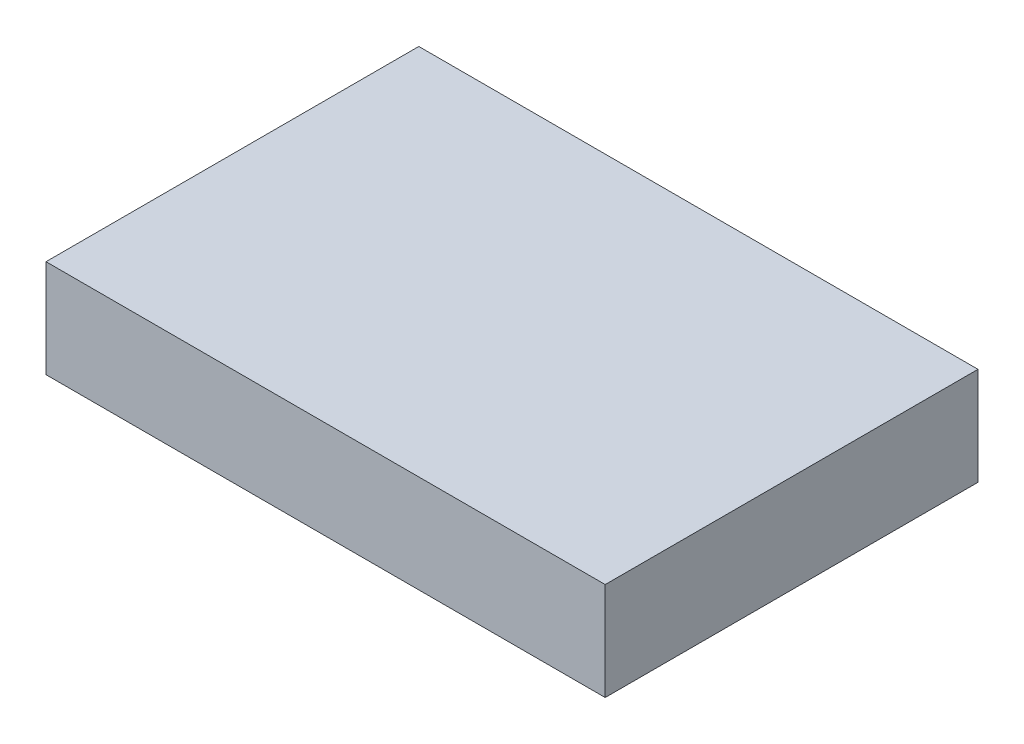
from build123d import *

# Parameters (mm, degrees)
SKETCH1_W           = 6
SKETCH1_H           = 4
BOSS_EXTRUDE1_DEPTH = 1.05


with BuildPart() as part:
    # Sketch1 → Boss-Extrude1 (new body)
    with BuildSketch(Plane(origin=(0, 0, 0), x_dir=(1, 0, 0), z_dir=(0, 1, 0))):
        Rectangle(SKETCH1_W, SKETCH1_H)
    extrude(amount=BOSS_EXTRUDE1_DEPTH)


solid = part.part
